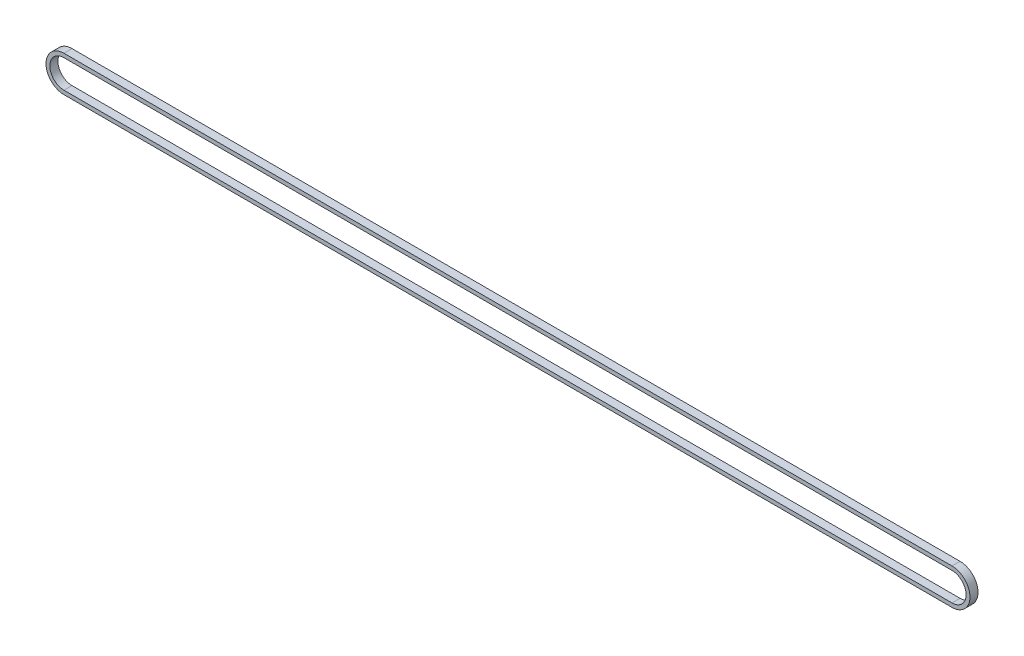
from build123d import *

# Parameters (mm, degrees)
EXTRUDE_THIN1_DEPTH = 2.5


with BuildPart() as part:
    # Sketch1 → Extrude-Thin1 (new body, symmetric)
    with BuildSketch(Plane.XY):
        with BuildLine():
            Line((551.8, -11.15), (0, -11.15))
            ThreePointArc((0, -11.15), (-11.15, 0), (0, 11.15))
            Line((0, 11.15), (551.8, 11.15))
            ThreePointArc((551.8, 11.15), (562.95, 0), (551.8, -11.15))
        make_face()
        with BuildLine():
            Line((551.8, -8.75), (0, -8.75))
            ThreePointArc((0, -8.75), (-8.75, 0), (0, 8.75))
            Line((0, 8.75), (551.8, 8.75))
            ThreePointArc((551.8, 8.75), (560.55, 0), (551.8, -8.75))
        make_face(mode=Mode.SUBTRACT)
    extrude(amount=EXTRUDE_THIN1_DEPTH, both=True)


solid = part.part
